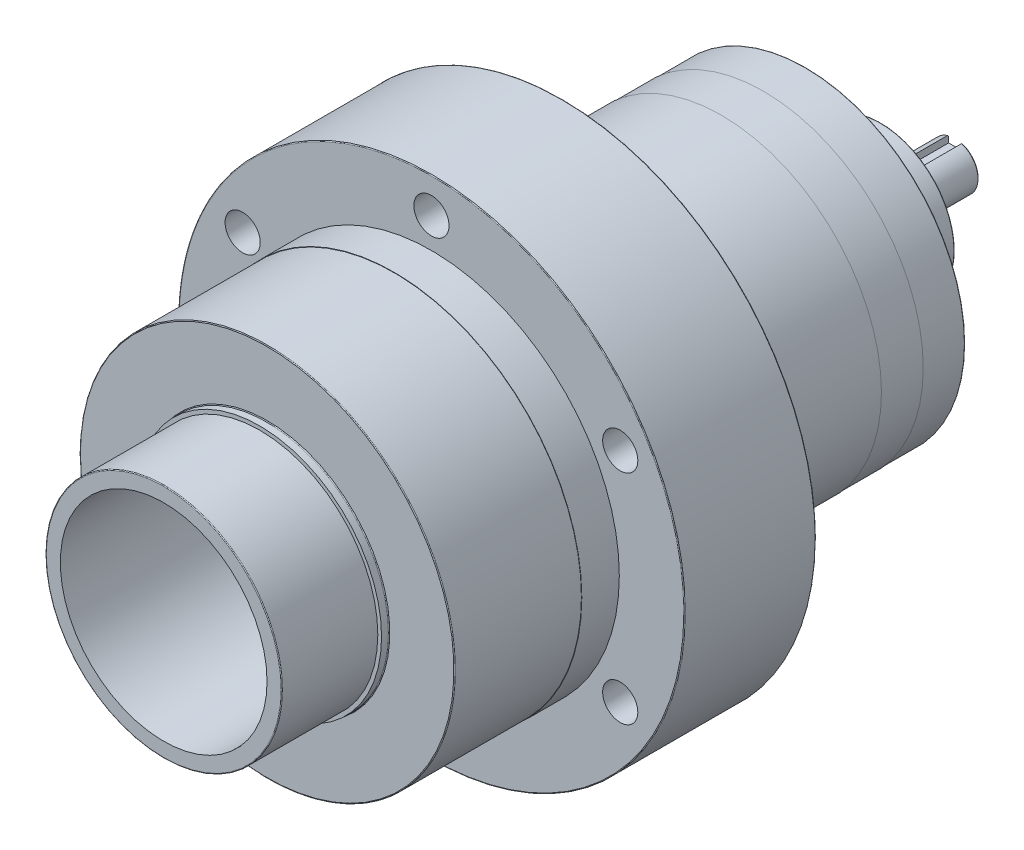
from build123d import *

# Parameters (mm, degrees)
SKETCH1_R                 = 41.275
EXTRUDE_E_DEPTH           = 35.052
SKETCH2_R                 = 41.275
SKETCH2_R_2               = 40.005
FROM_DRAWING_DEPTH        = 32.512
SKETCH3_R                 = 63.5
EXTRUDE_C_DEPTH           = 55.626
SKETCH4_R                 = 63.627
SKETCH4_R_2               = 63.5
BOSS_EXTRUDE3_DEPTH       = 12.7
SKETCH5_R                 = 85.725
EXTRUDE_B_DEPTH           = 44.45
CUT_EXTRUDE_START         = -88.9
SKETCH6_R                 = 35.0012
CUT_EXTRUDE_F_DEPTH       = 88.9
SKETCH8_R                 = 53.975
EXTRUDE_D_DEPTH           = 82.296
BOSS_EXTRUDE6_START       = 14.2875
SKETCH9_R                 = 54.102
BOSS_EXTRUDE6_DEPTH       = 14.2875
SKETCH10_R                = 54.229
BOSS_EXTRUDE7_DEPTH       = 53.721
SKETCH11_R                = 27.813
FROM_DRAWING_2_DEPTH      = 7.9248
SKETCH12_R                = 24.9936
EXTRUDE_Q_DEPTH           = 17.526
SKETCH13_R                = 7.9375
EXTRUDE_R_DEPTH           = 25.3492
HOLE_WIZARD_S_D           = 11.90498
HOLE_WIZARD_S_CBORE_D     = 18.25752
HOLE_WIZARD_S_CBORE_DEPTH = 11.1125
CIRPATTERN1_COUNT         = 6
SKETCH16_R                = 17.526
SKETCH16_R_2              = 7.9375
CUT_EXTRUDE3_DEPTH        = 12.7
CUT_EXTRUDE_T_REACH       = 82.531
CUT_EXTRUDE_T_END_RADIUS  = 7.9375
CHAMFER1_SIZE             = 0.381
FILLET1_R                 = 0.254


with BuildPart() as part:
    # Sketch1 → Extrude E (new body)
    with BuildSketch(Plane.XY):
        Circle(SKETCH1_R)
    extrude(amount=-EXTRUDE_E_DEPTH)

    # Sketch2 → from drawing (cut)
    with BuildSketch(Plane.XY):
        Circle(SKETCH2_R)
        Circle(SKETCH2_R_2, mode=Mode.SUBTRACT)
    extrude(amount=-FROM_DRAWING_DEPTH, mode=Mode.SUBTRACT)

    # Sketch3 → Extrude C (add)
    with BuildSketch(Plane(origin=(0, 0, -35.052), x_dir=(-1, 0, 0), z_dir=(0, 0, -1))):
        with Locations(Location((0, 0, 0), (0, 0, 180))):  # turned: the seam where the file's is
            Circle(SKETCH3_R)
    extrude(amount=EXTRUDE_C_DEPTH)

    # Sketch4 → Boss-Extrude3 (add)
    with BuildSketch(Plane.XY.offset(-77.978)):
        Circle(SKETCH4_R)
        Circle(SKETCH4_R_2, mode=Mode.SUBTRACT)
    extrude(amount=-BOSS_EXTRUDE3_DEPTH)

    # Sketch5 → Extrude B (add)
    with BuildSketch(Plane.XY.offset(-90.678)):
        Circle(SKETCH5_R)
    extrude(amount=-EXTRUDE_B_DEPTH)

    # Sketch6 → Cut-Extrude F (cut)
    with BuildSketch(Plane.XY.offset(CUT_EXTRUDE_START)):
        Circle(SKETCH6_R)
    extrude(amount=CUT_EXTRUDE_F_DEPTH, mode=Mode.SUBTRACT)

    # Sketch8 → Extrude D (add)
    with BuildSketch(Plane(origin=(0, 0, -135.128), x_dir=(-1, 0, 0), z_dir=(0, 0, -1))):
        with Locations(Location((0, 0, 0), (0, 0, 180))):  # turned: the seam where the file's is
            Circle(SKETCH8_R)
    extrude(amount=EXTRUDE_D_DEPTH)

    # Sketch9 → Boss-Extrude6 (add)
    with BuildSketch(Plane.XY.offset(-217.424).offset(BOSS_EXTRUDE6_START)):
        Circle(SKETCH9_R)
    extrude(amount=BOSS_EXTRUDE6_DEPTH)

    # Sketch10 → Boss-Extrude7 (add)
    with BuildSketch(Plane.XY.offset(-188.849)):
        Circle(SKETCH10_R)
    extrude(amount=BOSS_EXTRUDE7_DEPTH)

    # Sketch11 → from drawing 2 (add)
    with BuildSketch(Plane(origin=(0, 0, -217.424), x_dir=(-1, 0, 0), z_dir=(0, 0, -1))):
        with Locations(Location((0, 0, 0), (0, 0, 180))):  # turned: the seam where the file's is
            Circle(SKETCH11_R)
    extrude(amount=FROM_DRAWING_2_DEPTH)

    # Sketch12 → Extrude Q (add)
    with BuildSketch(Plane(origin=(0, 0, -225.3488), x_dir=(-1, 0, 0), z_dir=(0, 0, -1))):
        with Locations(Location((0, 0, 0), (0, 0, 180))):  # turned: the seam where the file's is
            Circle(SKETCH12_R)
    extrude(amount=EXTRUDE_Q_DEPTH)

    # Sketch13 → Extrude R (add)
    with BuildSketch(Plane(origin=(0, 0, -242.8748), x_dir=(-1, 0, 0), z_dir=(0, 0, -1))):
        with Locations(Location((0, 0, 0), (0, 0, 180))):  # turned: the seam where the file's is
            Circle(SKETCH13_R)
    extrude(amount=EXTRUDE_R_DEPTH)

    # Hole Wizard S (through all)
    with Locations(Plane(origin=(0, 0, -135.128), x_dir=(-1, 0, 0), z_dir=(0, 0, -1))):
        with Locations((0, -73.8251)):
            hole_wizard_s = CounterBoreHole(HOLE_WIZARD_S_D / 2, HOLE_WIZARD_S_CBORE_D / 2, HOLE_WIZARD_S_CBORE_DEPTH)

    # CirPattern1: Hole Wizard S ×6 about axis
    cirpattern1_axis = Axis((0, 0, 0), (0, 0, 1))
    for i in range(1, CIRPATTERN1_COUNT):
        add(hole_wizard_s.rotate(cirpattern1_axis, i * 360 / CIRPATTERN1_COUNT), mode=Mode.SUBTRACT)

    # Sketch16 → Cut-Extrude3 (cut)
    with BuildSketch(Plane(origin=(0, 0, -242.8748), x_dir=(-1, 0, 0), z_dir=(0, 0, -1))):
        Circle(SKETCH16_R)
        with Locations(Location((0, 0, 0), (0, 0, 180))):  # turned: the seam where the file's is
            Circle(SKETCH16_R_2, mode=Mode.SUBTRACT)
    extrude(amount=-CUT_EXTRUDE3_DEPTH, mode=Mode.SUBTRACT)

    # Cut-Extrude T: up to this cylinder (the profile starts inside it)
    cut_extrude_t_end = Plane(origin=(0, 0, -253.9365), z_dir=(0, 0, 1)) * Cylinder(CUT_EXTRUDE_T_END_RADIUS, 181.937, mode=Mode.PRIVATE)
    # Sketch17 → Cut-Extrude T (cut, up to the surface)
    with BuildSketch(Plane.XZ.offset(-5.1943), mode=Mode.PRIVATE) as cut_extrude_t_sk1:
        with BuildLine():
            Line((-2.3876, -268.224), (-2.3876, -239.649))
            ThreePointArc((-2.3876, -239.649), (0, -237.2614), (2.3876, -239.649))
            Line((2.3876, -239.649), (2.3876, -268.224))
            ThreePointArc((2.3876, -268.224), (0, -270.6116), (-2.3876, -268.224))
        make_face()
    cut_extrude_t_tool1 = extrude(cut_extrude_t_sk1.sketch, amount=-CUT_EXTRUDE_T_REACH, mode=Mode.PRIVATE) & cut_extrude_t_end
    add(cut_extrude_t_tool1.solids().sort_by_distance((0, 5.1943, -253.9365))[0], mode=Mode.SUBTRACT)

    # Chamfer1
    chamfer1_edges = [part.edges().sort_by_distance(p)[0] for p in [
        (-4.693204196, -6.401385836, -268.224),
    ]]
    chamfer(chamfer1_edges, length=CHAMFER1_SIZE)

    # Fillet1
    fillet1_edges = [part.edges().sort_by_distance(p)[0] for p in [
        (-59.370032037, -44.818288065, -135.128),
        (-40.005, 0, 0),
        (-63.5, 0, -35.052),
        (-85.725, 0, -90.678),
        (-85.725, 0, -135.128),
        (-53.975, 0, -217.424),
        (-41.275, 0, -35.052),
        (-54.229, 0, -135.128),
        (-27.813, 0, -217.424),
        (-27.813, 0, -225.3488),
        (-24.9936, 0, -225.3488),
        (-24.9936, 0, -242.8748),
        (9.12876, -73.8251, -135.128),
        (68.498792037, -29.006811935, -135.128),
        (59.370032037, 44.818288065, -135.128),
        (-9.12876, 73.8251, -135.128),
        (-68.498792037, 29.006811935, -135.128),
    ]]
    fillet(fillet1_edges, radius=FILLET1_R)


solid = part.part
